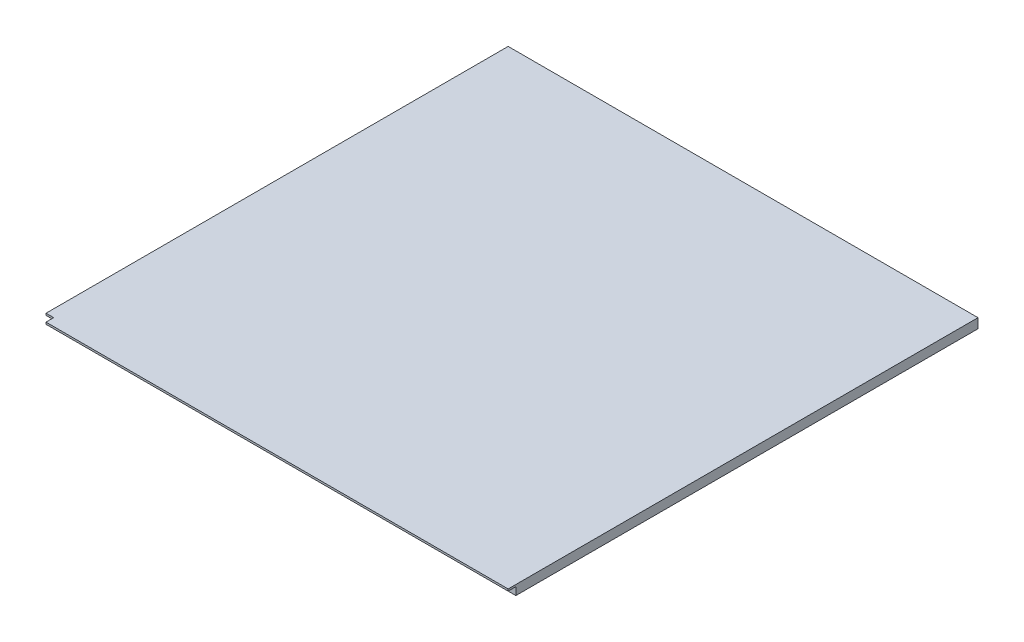
from build123d import *

# Parameters (mm, degrees)
SKETCH1_W           = 152.4
SKETCH1_H           = 152.4
BOSS_EXTRUDE1_DEPTH = 3.175
BOSS_EXTRUDE2_DEPTH = 0.635
SKETCH3_W           = 2.54
SKETCH3_H           = 2.54
CUT_EXTRUDE1_DEPTH  = 4.175


with BuildPart() as part:
    # Sketch1 → Boss-Extrude1 (new body)
    with BuildSketch(Plane(origin=(0, 0, 0), x_dir=(1, 0, 0), z_dir=(0, 1, 0))):
        with Locations((76.2, 76.2)):
            Rectangle(SKETCH1_W, SKETCH1_H)
    extrude(amount=BOSS_EXTRUDE1_DEPTH)

    # Sketch2 → Boss-Extrude2 (add)
    with BuildSketch(Plane(origin=(0, 3.175, 0), x_dir=(1, 0, 0), z_dir=(0, 1, 0))):
        Polygon((0, 152.4), (-2.54, 152.4), (-2.54, -2.54), (152.4, -2.54), (152.4, 0), (0, 0), align=None)
    extrude(amount=-BOSS_EXTRUDE2_DEPTH)

    # Sketch3 → Cut-Extrude1 (cut, through all)
    with BuildSketch(Plane(origin=(0, 3.175, 0), x_dir=(1, 0, 0), z_dir=(0, 1, 0))):
        with Locations((-1.27, -1.27)):
            Rectangle(SKETCH3_W, SKETCH3_H)
    extrude(amount=-CUT_EXTRUDE1_DEPTH, mode=Mode.SUBTRACT)


solid = part.part
